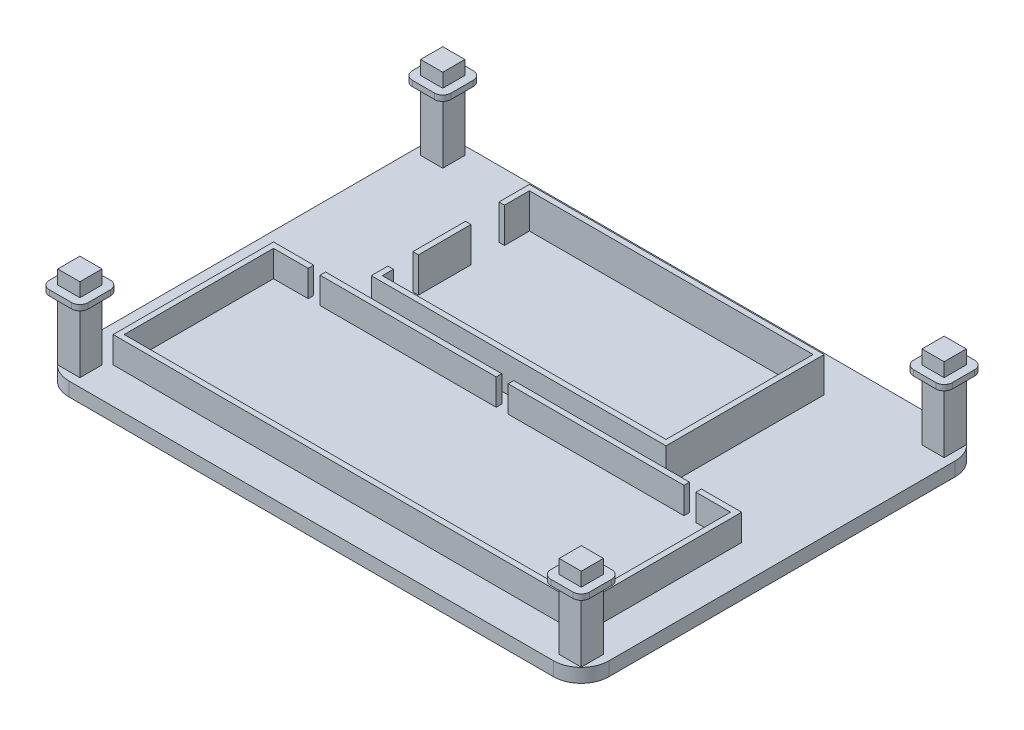
from build123d import *

# Parameters (mm, degrees)
SKETCH1_W            = 195
SKETCH1_H            = 145
BOSS_EXTRUDE1_DEPTH  = 5
SKETCH2_W            = 63.6
SKETCH2_H            = 2
SKETCH2_W_2          = 63.5
BOSS_EXTRUDE2_DEPTH  = 9.5
SKETCH4_W            = 8
SKETCH4_H            = 8
BOSS_EXTRUDE3_DEPTH  = 30
SKETCH3_W            = 2
SKETCH3_H            = 19
BOSS_EXTRUDE11_DEPTH = 12.6
SKETCH8_W            = 14
SKETCH8_H            = 14
SKETCH8_W_2          = 8
SKETCH8_H_2          = 8
BOSS_EXTRUDE12_DEPTH = 2
FILLET2_R            = 10
FILLET3_R            = 3


with BuildPart() as part:
    # Sketch1 → Boss-Extrude1 (new body)
    with BuildSketch(Plane(origin=(0, 0, 0), x_dir=(1, 0, 0), z_dir=(0, 1, 0))):
        Rectangle(SKETCH1_W, SKETCH1_H)
    extrude(amount=BOSS_EXTRUDE1_DEPTH)

    # Sketch2 → Boss-Extrude2 (add)
    with BuildSketch(Plane(origin=(0, 5, 0), x_dir=(1, 0, 0), z_dir=(0, 1, 0))):
        Polygon((-82.5, -57.5), (-82.5, -3.6), (-70, -3.6), (-70, -1.6), (-84.5, -1.6), (-84.5, -59.5), (84.5, -59.5), (84.5, -1.6), (70, -1.6), (70, -3.6), (82.5, -3.6), (82.5, -57.5), align=None)
        with Locations((-33.9, -2.6)):
            Rectangle(SKETCH2_W, SKETCH2_H)
        with Locations((33.95, -2.6)):
            Rectangle(SKETCH2_W_2, SKETCH2_H)
    extrude(amount=BOSS_EXTRUDE2_DEPTH)

    # Sketch4 → Boss-Extrude3 (add)
    with BuildSketch(Plane(origin=(0, 5, 0), x_dir=(1, 0, 0), z_dir=(0, 1, 0))):
        with Locations((-90.5, -65.5)):
            Rectangle(SKETCH4_W, SKETCH4_H)
        with Locations((90.5, -65.5)):
            Rectangle(SKETCH4_W, SKETCH4_H)
        with Locations((90.5, 65.5)):
            Rectangle(SKETCH4_W, SKETCH4_H)
        with Locations((-90.5, 65.5)):
            Rectangle(SKETCH4_W, SKETCH4_H)
    extrude(amount=BOSS_EXTRUDE3_DEPTH)

    # Sketch3 → Boss-Extrude11 (add)
    with BuildSketch(Plane(origin=(0, 5, 0), x_dir=(1, 0, 0), z_dir=(0, 1, 0))):
        with Locations((-52.2, 26.9)):
            Rectangle(SKETCH3_W, SKETCH3_H)
        Polygon((-51.2, 48.5), (-51.2, 57.5), (51.2, 57.5), (51.2, 4.4), (-51.2, 4.4), (-51.2, 8.4), (-53.2, 8.4), (-53.2, 2.4), (53.2, 2.4), (53.2, 59.5), (-53.2, 59.5), (-53.2, 48.5), align=None)
    extrude(amount=BOSS_EXTRUDE11_DEPTH)

    # Sketch8 → Boss-Extrude12 (add)
    with BuildSketch(Plane(origin=(0, 30, 0), x_dir=(1, 0, 0), z_dir=(0, 1, 0))):
        with Locations((90.5, 65.5)):
            Rectangle(SKETCH8_W, SKETCH8_H)
        with Locations((90.5, 65.5)):
            Rectangle(SKETCH8_W_2, SKETCH8_H_2, mode=Mode.SUBTRACT)
        with Locations((90.5, -65.5)):
            Rectangle(SKETCH8_W, SKETCH8_H)
        with Locations((90.5, -65.5)):
            Rectangle(SKETCH8_W_2, SKETCH8_H_2, mode=Mode.SUBTRACT)
        with Locations((-90.5, -65.5)):
            Rectangle(SKETCH8_W, SKETCH8_H)
        with Locations((-90.5, -65.5)):
            Rectangle(SKETCH8_W_2, SKETCH8_H_2, mode=Mode.SUBTRACT)
        with Locations((-90.5, 65.5)):
            Rectangle(SKETCH8_W, SKETCH8_H)
        with Locations((-90.5, 65.5)):
            Rectangle(SKETCH8_W_2, SKETCH8_H_2, mode=Mode.SUBTRACT)
    extrude(amount=-BOSS_EXTRUDE12_DEPTH)

    # Fillet2
    fillet2_edges = [part.edges().sort_by_distance(p)[0] for p in [
        (-97.5, 2.5, -72.5),
        (97.5, 2.5, -72.5),
        (97.5, 2.5, 72.5),
        (-97.5, 2.5, 72.5),
    ]]
    fillet(fillet2_edges, radius=FILLET2_R)

    # Fillet3
    fillet3_edges = [part.edges().sort_by_distance(p)[0] for p in [
        (97.5, 29, -58.5),
        (83.5, 29, -58.5),
        (83.5, 29, -72.5),
        (97.5, 29, -72.5),
        (83.5, 29, 58.5),
        (97.5, 29, 58.5),
        (97.5, 29, 72.5),
        (83.5, 29, 72.5),
        (-97.5, 29, 58.5),
        (-83.5, 29, 58.5),
        (-83.5, 29, 72.5),
        (-97.5, 29, 72.5),
        (-83.5, 29, -58.5),
        (-97.5, 29, -58.5),
        (-97.5, 29, -72.5),
        (-83.5, 29, -72.5),
    ]]
    fillet(fillet3_edges, radius=FILLET3_R)


solid = part.part
